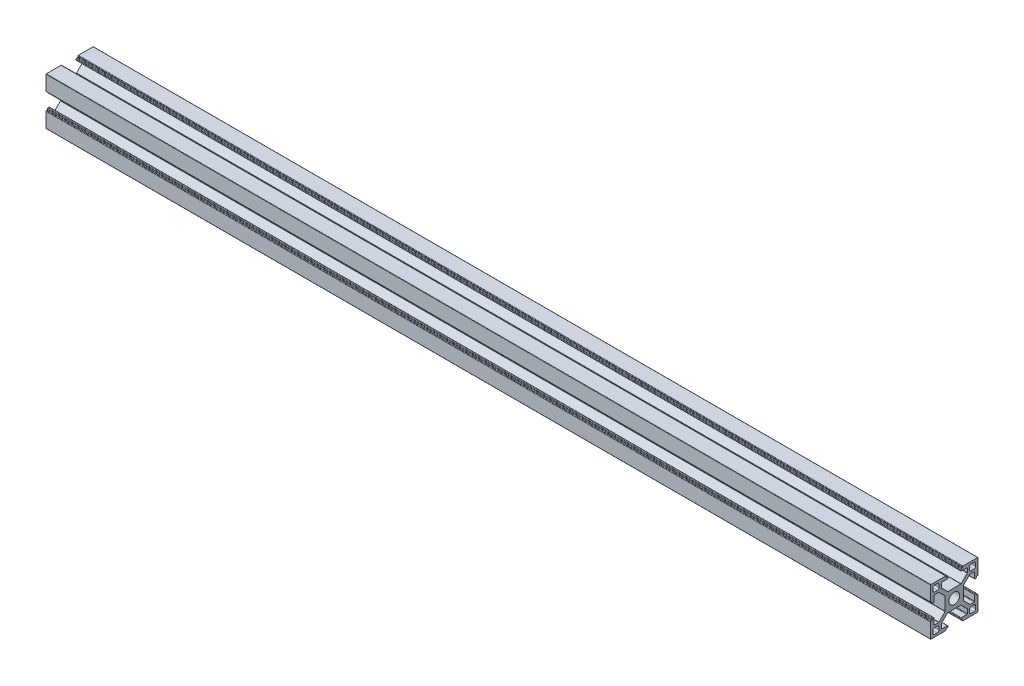
from build123d import *

# Parameters (mm, degrees)
SKETCH_11_R          = 3.4
MEMBER_3030A_1_DEPTH = 560


with BuildPart() as part:
    # 草图11 → Member 3030a _1 (new body)
    with BuildSketch(Plane.YZ):
        with BuildLine():
            Line((0, 5.8), (-4.120101013, 5.8))
            ThreePointArc((-4.120101013, 5.8), (-4.234906042, 5.82283614), (-4.332233047, 5.887867966))
            Line((-4.332233047, 5.887867966), (-8.162132034, 9.717766953))
            ThreePointArc((-8.162132034, 9.717766953), (-8.22716386, 9.815093958), (-8.25, 9.929898987))
            Line((-8.25, 9.929898987), (-8.25, 12.5))
            ThreePointArc((-8.25, 12.5), (-8.162132034, 12.712132034), (-7.95, 12.8))
            Line((-7.95, 12.8), (-4.4, 12.8))
            ThreePointArc((-4.4, 12.8), (-4.187867966, 12.887867966), (-4.1, 13.1))
            Line((-4.1, 13.1), (-4.1, 13.7))
            ThreePointArc((-4.1, 13.7), (-4.187867966, 13.912132034), (-4.4, 14))
            Line((-4.4, 14), (-4.9, 14))
            ThreePointArc((-4.9, 14), (-5.112132034, 14.087867966), (-5.2, 14.3))
            Line((-5.2, 14.3), (-5.2, 14.7))
            ThreePointArc((-5.2, 14.7), (-5.287867966, 14.912132034), (-5.5, 15))
            Line((-5.5, 15), (-14.8, 15))
            ThreePointArc((-14.8, 15), (-14.941421356, 14.941421356), (-15, 14.8))
            Line((-15, 14.8), (-15, 5.5))
            ThreePointArc((-15, 5.5), (-14.912132034, 5.287867966), (-14.7, 5.2))
            Line((-14.7, 5.2), (-14.3, 5.2))
            ThreePointArc((-14.3, 5.2), (-14.087867966, 5.112132034), (-14, 4.9))
            Line((-14, 4.9), (-14, 4.4))
            ThreePointArc((-14, 4.4), (-13.912132034, 4.187867966), (-13.7, 4.1))
            Line((-13.7, 4.1), (-13.1, 4.1))
            ThreePointArc((-13.1, 4.1), (-12.887867966, 4.187867966), (-12.8, 4.4))
            Line((-12.8, 4.4), (-12.8, 7.95))
            ThreePointArc((-12.8, 7.95), (-12.712132034, 8.162132034), (-12.5, 8.25))
            Line((-12.5, 8.25), (-9.929898987, 8.25))
            ThreePointArc((-9.929898987, 8.25), (-9.815093957, 8.227163859), (-9.717766953, 8.162132034))
            Line((-9.717766953, 8.162132034), (-5.887867966, 4.332233047))
            ThreePointArc((-5.887867966, 4.332233047), (-5.82283614, 4.234906042), (-5.8, 4.120101013))
            Line((-5.8, 4.120101013), (-5.8, 0))
            Line((-5.8, 0), (-5.8, -4.120101013))
            ThreePointArc((-5.8, -4.120101013), (-5.82283614, -4.234906042), (-5.887867966, -4.332233047))
            Line((-5.887867966, -4.332233047), (-9.717766953, -8.162132034))
            ThreePointArc((-9.717766953, -8.162132034), (-9.815093958, -8.22716386), (-9.929898988, -8.25))
            Line((-9.929898988, -8.25), (-12.5, -8.25))
            ThreePointArc((-12.5, -8.25), (-12.712132034, -8.162132034), (-12.8, -7.95))
            Line((-12.8, -7.95), (-12.8, -4.4))
            ThreePointArc((-12.8, -4.4), (-12.887867966, -4.187867966), (-13.1, -4.1))
            Line((-13.1, -4.1), (-13.7, -4.1))
            ThreePointArc((-13.7, -4.1), (-13.912132034, -4.187867966), (-14, -4.4))
            Line((-14, -4.4), (-14, -4.9))
            ThreePointArc((-14, -4.9), (-14.087867966, -5.112132034), (-14.3, -5.2))
            Line((-14.3, -5.2), (-14.7, -5.2))
            ThreePointArc((-14.7, -5.2), (-14.912132034, -5.287867966), (-15, -5.5))
            Line((-15, -5.5), (-15, -14.8))
            ThreePointArc((-15, -14.8), (-14.941421356, -14.941421356), (-14.8, -15))
            Line((-14.8, -15), (-5.5, -15))
            ThreePointArc((-5.5, -15), (-5.287867966, -14.912132034), (-5.2, -14.7))
            Line((-5.2, -14.7), (-5.2, -14.3))
            ThreePointArc((-5.2, -14.3), (-5.112132034, -14.087867966), (-4.9, -14))
            Line((-4.9, -14), (-4.4, -14))
            ThreePointArc((-4.4, -14), (-4.187867966, -13.912132034), (-4.1, -13.7))
            Line((-4.1, -13.7), (-4.1, -13.1))
            ThreePointArc((-4.1, -13.1), (-4.187867966, -12.887867966), (-4.4, -12.8))
            Line((-4.4, -12.8), (-7.95, -12.8))
            ThreePointArc((-7.95, -12.8), (-8.162132034, -12.712132034), (-8.25, -12.5))
            Line((-8.25, -12.5), (-8.25, -9.929898987))
            ThreePointArc((-8.25, -9.929898987), (-8.22716386, -9.815093958), (-8.162132034, -9.717766953))
            Line((-8.162132034, -9.717766953), (-4.332233047, -5.887867966))
            ThreePointArc((-4.332233047, -5.887867966), (-4.234906042, -5.82283614), (-4.120101013, -5.8))
            Line((-4.120101013, -5.8), (0, -5.8))
            Line((0, -5.8), (4.120101013, -5.8))
            ThreePointArc((4.120101013, -5.8), (4.234906042, -5.82283614), (4.332233047, -5.887867966))
            Line((4.332233047, -5.887867966), (8.162132034, -9.717766953))
            ThreePointArc((8.162132034, -9.717766953), (8.22716386, -9.815093958), (8.25, -9.929898987))
            Line((8.25, -9.929898987), (8.25, -12.5))
            ThreePointArc((8.25, -12.5), (8.162132034, -12.712132034), (7.95, -12.8))
            Line((7.95, -12.8), (4.4, -12.8))
            ThreePointArc((4.4, -12.8), (4.187867966, -12.887867966), (4.1, -13.1))
            Line((4.1, -13.1), (4.1, -13.7))
            ThreePointArc((4.1, -13.7), (4.187867966, -13.912132034), (4.4, -14))
            Line((4.4, -14), (4.9, -14))
            ThreePointArc((4.9, -14), (5.112132034, -14.087867966), (5.2, -14.3))
            Line((5.2, -14.3), (5.2, -14.7))
            ThreePointArc((5.2, -14.7), (5.287867966, -14.912132034), (5.5, -15))
            Line((5.5, -15), (14.8, -15))
            ThreePointArc((14.8, -15), (14.941421356, -14.941421356), (15, -14.8))
            Line((15, -14.8), (15, -5.5))
            ThreePointArc((15, -5.5), (14.912132034, -5.287867966), (14.7, -5.2))
            Line((14.7, -5.2), (14.3, -5.2))
            ThreePointArc((14.3, -5.2), (14.087867966, -5.112132034), (14, -4.9))
            Line((14, -4.9), (14, -4.4))
            ThreePointArc((14, -4.4), (13.912132034, -4.187867966), (13.7, -4.1))
            Line((13.7, -4.1), (13.1, -4.1))
            ThreePointArc((13.1, -4.1), (12.887867966, -4.187867966), (12.8, -4.4))
            Line((12.8, -4.4), (12.8, -7.95))
            ThreePointArc((12.8, -7.95), (12.712132034, -8.162132034), (12.5, -8.25))
            Line((12.5, -8.25), (9.929898987, -8.25))
            ThreePointArc((9.929898987, -8.25), (9.815093957, -8.227163859), (9.717766953, -8.162132034))
            Line((9.717766953, -8.162132034), (5.887867966, -4.332233047))
            ThreePointArc((5.887867966, -4.332233047), (5.82283614, -4.234906042), (5.8, -4.120101013))
            Line((5.8, -4.120101013), (5.8, 0))
            Line((5.8, 0), (5.8, 4.120101013))
            ThreePointArc((5.8, 4.120101013), (5.82283614, 4.234906042), (5.887867966, 4.332233047))
            Line((5.887867966, 4.332233047), (9.805634919, 8.25))
            Line((9.805634919, 8.25), (12.5, 8.25))
            ThreePointArc((12.5, 8.25), (12.712132034, 8.162132034), (12.8, 7.95))
            Line((12.8, 7.95), (12.8, 4.4))
            ThreePointArc((12.8, 4.4), (12.887867966, 4.187867966), (13.1, 4.1))
            Line((13.1, 4.1), (13.7, 4.1))
            ThreePointArc((13.7, 4.1), (13.912132034, 4.187867966), (14, 4.4))
            Line((14, 4.4), (14, 4.9))
            ThreePointArc((14, 4.9), (14.087867966, 5.112132034), (14.3, 5.2))
            Line((14.3, 5.2), (14.7, 5.2))
            ThreePointArc((14.7, 5.2), (14.912132034, 5.287867966), (15, 5.5))
            Line((15, 5.5), (15, 14.8))
            ThreePointArc((15, 14.8), (14.941421356, 14.941421356), (14.8, 15))
            Line((14.8, 15), (5.5, 15))
            ThreePointArc((5.5, 15), (5.287867966, 14.912132034), (5.2, 14.7))
            Line((5.2, 14.7), (5.2, 14.3))
            ThreePointArc((5.2, 14.3), (5.112132034, 14.087867966), (4.9, 14))
            Line((4.9, 14), (4.4, 14))
            ThreePointArc((4.4, 14), (4.187867966, 13.912132034), (4.1, 13.7))
            Line((4.1, 13.7), (4.1, 13.1))
            ThreePointArc((4.1, 13.1), (4.187867966, 12.887867966), (4.4, 12.8))
            Line((4.4, 12.8), (7.95, 12.8))
            ThreePointArc((7.95, 12.8), (8.162132034, 12.712132034), (8.25, 12.5))
            Line((8.25, 12.5), (8.25, 9.929898987))
            ThreePointArc((8.25, 9.929898987), (8.22716386, 9.815093958), (8.162132034, 9.717766953))
            Line((8.162132034, 9.717766953), (4.332233047, 5.887867966))
            ThreePointArc((4.332233047, 5.887867966), (4.234906042, 5.82283614), (4.120101013, 5.8))
            Line((4.120101013, 5.8), (0, 5.8))
        make_face()
        Circle(SKETCH_11_R, mode=Mode.SUBTRACT)
        with BuildLine():
            Line((-10.75, -13.5), (-12.5, -13.5))
            ThreePointArc((-12.5, -13.5), (-13.207106781, -13.207106781), (-13.5, -12.5))
            Line((-13.5, -12.5), (-13.5, -10.75))
            ThreePointArc((-13.5, -10.75), (-13.207106781, -10.042893219), (-12.5, -9.75))
            Line((-12.5, -9.75), (-10.75, -9.75))
            ThreePointArc((-10.75, -9.75), (-10.042893219, -10.042893219), (-9.75, -10.75))
            Line((-9.75, -10.75), (-9.75, -12.5))
            ThreePointArc((-9.75, -12.5), (-10.042893219, -13.207106781), (-10.75, -13.5))
        make_face(mode=Mode.SUBTRACT)
        with BuildLine():
            Line((10.75, -13.5), (12.5, -13.5))
            ThreePointArc((12.5, -13.5), (13.207106781, -13.207106781), (13.5, -12.5))
            Line((13.5, -12.5), (13.5, -10.75))
            ThreePointArc((13.5, -10.75), (13.207106781, -10.042893219), (12.5, -9.75))
            Line((12.5, -9.75), (10.75, -9.75))
            ThreePointArc((10.75, -9.75), (10.042893219, -10.042893219), (9.75, -10.75))
            Line((9.75, -10.75), (9.75, -12.5))
            ThreePointArc((9.75, -12.5), (10.042893219, -13.207106781), (10.75, -13.5))
        make_face(mode=Mode.SUBTRACT)
        with BuildLine():
            Line((-10.75, 13.5), (-12.5, 13.5))
            ThreePointArc((-12.5, 13.5), (-13.207106781, 13.207106781), (-13.5, 12.5))
            Line((-13.5, 12.5), (-13.5, 10.75))
            ThreePointArc((-13.5, 10.75), (-13.207106781, 10.042893219), (-12.5, 9.75))
            Line((-12.5, 9.75), (-10.75, 9.75))
            ThreePointArc((-10.75, 9.75), (-10.042893219, 10.042893219), (-9.75, 10.75))
            Line((-9.75, 10.75), (-9.75, 12.5))
            ThreePointArc((-9.75, 12.5), (-10.042893219, 13.207106781), (-10.75, 13.5))
        make_face(mode=Mode.SUBTRACT)
        with BuildLine():
            Line((10.75, 13.5), (12.5, 13.5))
            ThreePointArc((12.5, 13.5), (13.207106781, 13.207106781), (13.5, 12.5))
            Line((13.5, 12.5), (13.5, 10.75))
            ThreePointArc((13.5, 10.75), (13.207106781, 10.042893219), (12.5, 9.75))
            Line((12.5, 9.75), (10.75, 9.75))
            ThreePointArc((10.75, 9.75), (10.042893219, 10.042893219), (9.75, 10.75))
            Line((9.75, 10.75), (9.75, 12.5))
            ThreePointArc((9.75, 12.5), (10.042893219, 13.207106781), (10.75, 13.5))
        make_face(mode=Mode.SUBTRACT)
    extrude(amount=MEMBER_3030A_1_DEPTH)


solid = part.part
